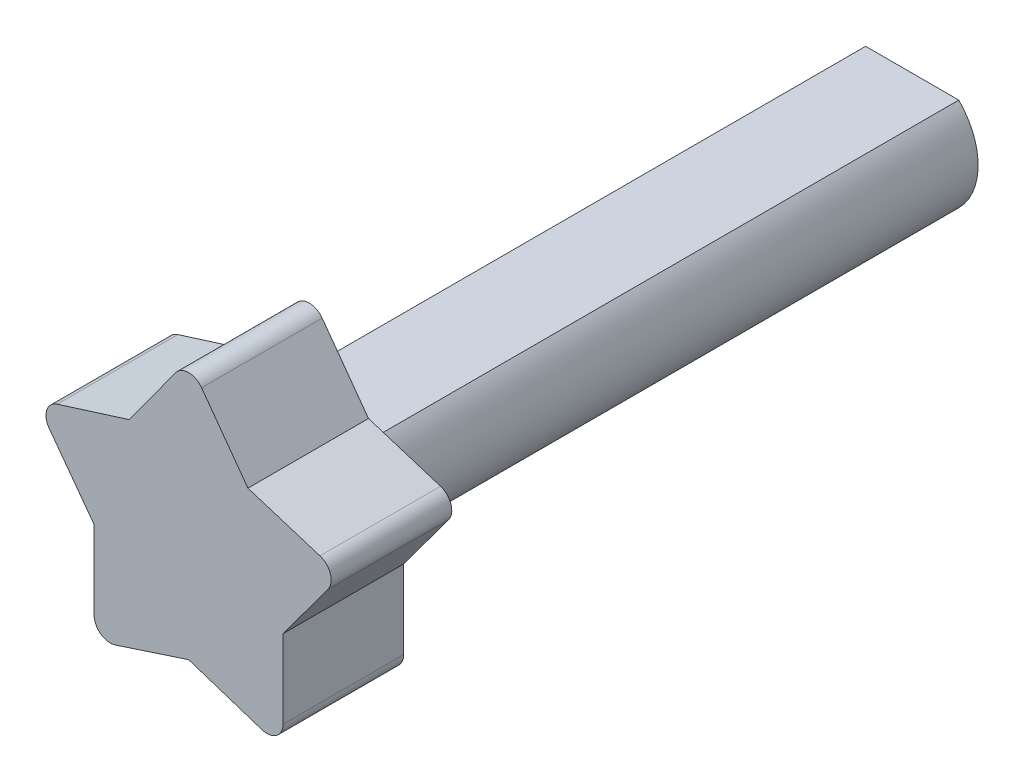
from build123d import *

# Parameters (mm, degrees)
BOSS_EXTRUDE1_DEPTH = 114.3
BOSS_EXTRUDE2_DEPTH = 19.05


with BuildPart() as part:
    # Sketch1 → Boss-Extrude1 (new body)
    with BuildSketch(Plane.XY):
        with BuildLine():
            Line((-7.341079337, -7.302244278), (7.377825429, -7.302244278))
            ThreePointArc((7.377825429, -7.302244278), (10.432373046, 0.065920801), (7.377825429, 7.434085879))
            Line((7.377825429, 7.434085879), (-7.341079337, 7.434085879))
            ThreePointArc((-7.341079337, 7.434085879), (-10.395626954, 0.065920801), (-7.341079337, -7.302244278))
        make_face()
    extrude(amount=-BOSS_EXTRUDE1_DEPTH)

    # Sketch2 → Boss-Extrude2 (add)
    with BuildSketch(Plane.XY):
        with BuildLine():
            Line((-11.594830289, -19.452818555), (0, -15.661809823))
            Line((0, -15.661809823), (11.594830289, -19.452818555))
            ThreePointArc((11.594830289, -19.452818555), (13.875262434, -19.094861422), (14.924180561, -17.038584484))
            Line((14.924180561, -17.038584484), (14.924180561, -4.642008184))
            Line((14.924180561, -4.642008184), (22.032123103, 4.98159964))
            ThreePointArc((22.032123103, 4.98159964), (22.40396274, 7.277739061), (20.750529859, 8.913795499))
            Line((20.750529859, 8.913795499), (9.373214352, 12.489409744))
            Line((9.373214352, 12.489409744), (2.054903166, 22.56220095))
            ThreePointArc((2.054903166, 22.56220095), (0, 23.609226409), (-2.054903166, 22.56220095))
            Line((-2.054903166, 22.56220095), (-9.373214352, 12.489409744))
            Line((-9.373214352, 12.489409744), (-20.750529859, 8.913795499))
            ThreePointArc((-20.750529859, 8.913795499), (-22.40396274, 7.277739061), (-22.032123103, 4.98159964))
            Line((-22.032123103, 4.98159964), (-14.924180561, -4.642008184))
            Line((-14.924180561, -4.642008184), (-14.924180561, -17.038584484))
            ThreePointArc((-14.924180561, -17.038584484), (-13.875262434, -19.094861422), (-11.594830289, -19.452818555))
        make_face()
    extrude(amount=-BOSS_EXTRUDE2_DEPTH)


solid = part.part
